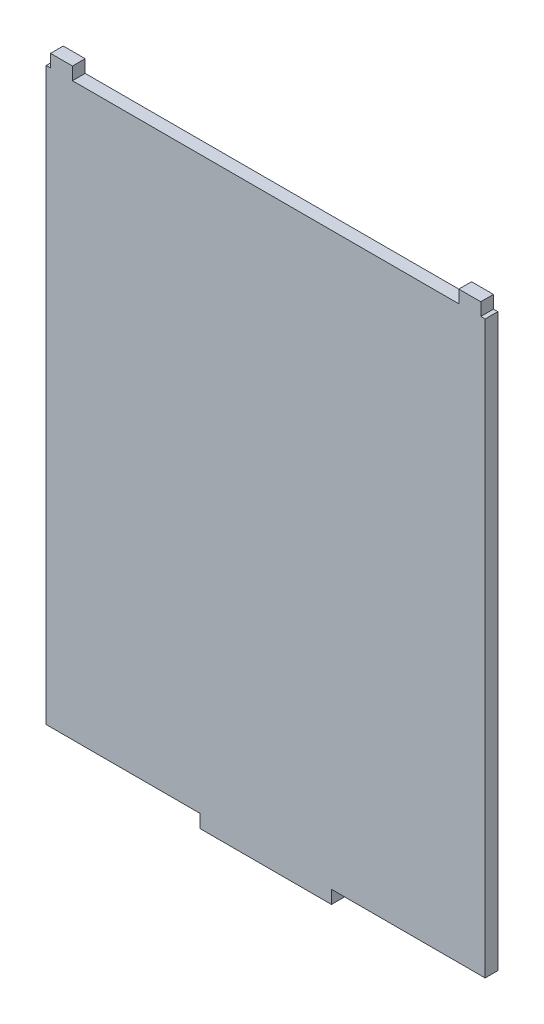
from build123d import *

# Parameters (mm, degrees)
EXTRUDE_1_DEPTH = 2.9


with BuildPart() as part:
    # 草图1 → 凸台-拉伸1 (new body)
    with BuildSketch(Plane.XY):
        Polygon((65, 0), (100, 0), (100, 130), (99, 130), (99, 132.9), (95, 132.9), (94, 132.9), (94, 130), (6, 130), (6, 132.9), (5, 132.9), (1, 132.9), (1, 130), (0, 130), (0, 0), (35, 0), (35, -3), (50, -3), (65, -3), align=None)
    extrude(amount=EXTRUDE_1_DEPTH)


solid = part.part
